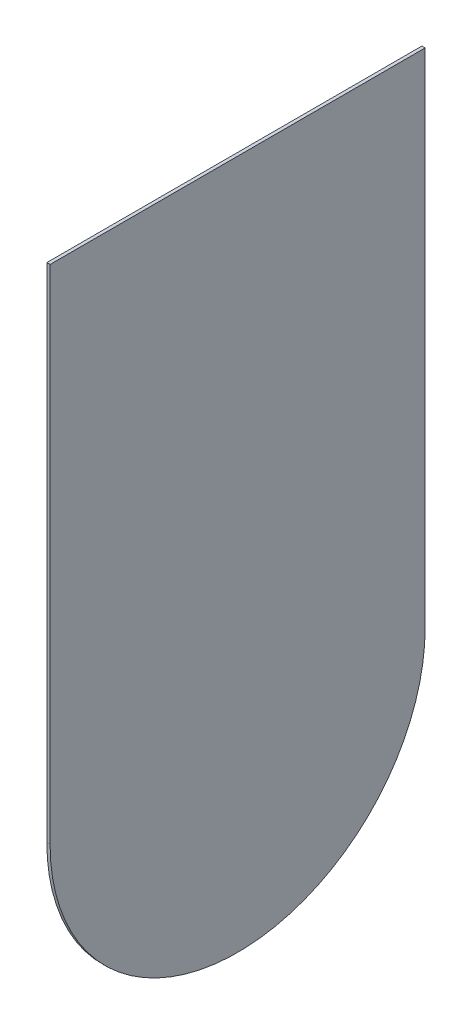
from build123d import *

# Parameters (mm, degrees)
SKETCH1_W           = 25.4
SKETCH1_H           = 34
BOSS_EXTRUDE1_DEPTH = 0.22


with BuildPart() as part:
    # Sketch1 → Boss-Extrude1 (new body)
    with BuildSketch(Plane(origin=(0, 0, 0), x_dir=(0, 0, -1), z_dir=(1, 0, 0))):
        with BuildLine():
            Line((-13.316504854, -12.946601942), (12.083495146, -12.946601942))
            ThreePointArc((12.083495146, -12.946601942), (-0.616504854, -25.646601942), (-13.316504854, -12.946601942))
        make_face()
        with Locations((-0.616504854, 4.053398058)):
            Rectangle(SKETCH1_W, SKETCH1_H)
    extrude(amount=BOSS_EXTRUDE1_DEPTH)


solid = part.part
